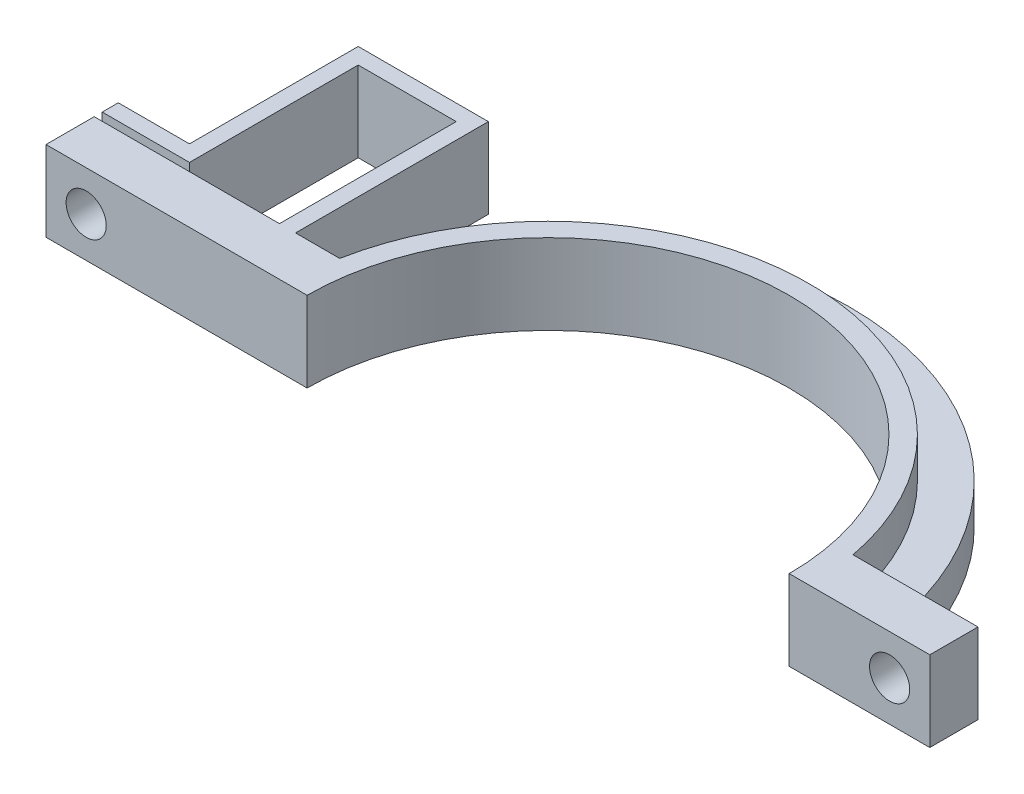
from build123d import *

# Parameters (mm, degrees)
BOSS_EXTRUDE1_DEPTH = 10
BOSS_EXTRUDE2_DEPTH = 5
BOSS_EXTRUDE5_DEPTH = 10
SKETCH3_R           = 2.5
CUT_EXTRUDE4_DEPTH  = 30


with BuildPart() as part:
    # Sketch1 → Boss-Extrude1 (new body)
    with BuildSketch(Plane(origin=(0, 0, 0), x_dir=(1, 0, 0), z_dir=(0, 1, 0))):
        with BuildLine():
            Line((47.5, 6), (31.941352507, 6))
            ThreePointArc((31.941352507, 6), (0, 32.5), (-31.941352507, 6))
            Line((-31.941352507, 6), (-62.5, 6))
            Line((-62.5, 6), (-62.5, 0))
            Line((-62.5, 0), (-30, 0))
            ThreePointArc((-30, 0), (0, 30), (30, 0))
            Line((30, 0), (47.5, 0))
            Line((47.5, 0), (47.5, 6))
        make_face()
    extrude(amount=BOSS_EXTRUDE1_DEPTH)

    # Sketch5 → Boss-Extrude2 (add)
    with BuildSketch(Plane(origin=(0, 0, 0), x_dir=(1, 0, 0), z_dir=(0, 1, 0))):
        with BuildLine():
            ThreePointArc((37.5, 0), (0, 37.5), (-37.5, 0))
            Line((-37.5, 0), (-32.5, 0))
            ThreePointArc((-32.5, 0), (0, 32.5), (32.5, 0))
            Line((32.5, 0), (37.5, 0))
        make_face()
    extrude(amount=BOSS_EXTRUDE2_DEPTH)

    # Sketch1_5 → Boss-Extrude5 (add)
    with BuildSketch(Plane(origin=(0, 0, 0), x_dir=(1, 0, 0), z_dir=(0, 1, 0))):
        Polygon((-39.441352507, 6), (-37.441352507, 6), (-37.441352507, 30), (-53.641352507, 30), (-53.641352507, 9), (-62.5, 9), (-62.5, 7), (-51.641352507, 7), (-51.641352507, 28), (-39.441352507, 28), align=None)
    extrude(amount=BOSS_EXTRUDE5_DEPTH)

    # Sketch3 → Cut-Extrude4 (cut)
    with BuildSketch(Plane.XY):
        with Locations((-57.5, 5)):
            Circle(SKETCH3_R)
        with Locations((42.5, 5)):
            Circle(SKETCH3_R)
    extrude(amount=-CUT_EXTRUDE4_DEPTH, mode=Mode.SUBTRACT)


solid = part.part
